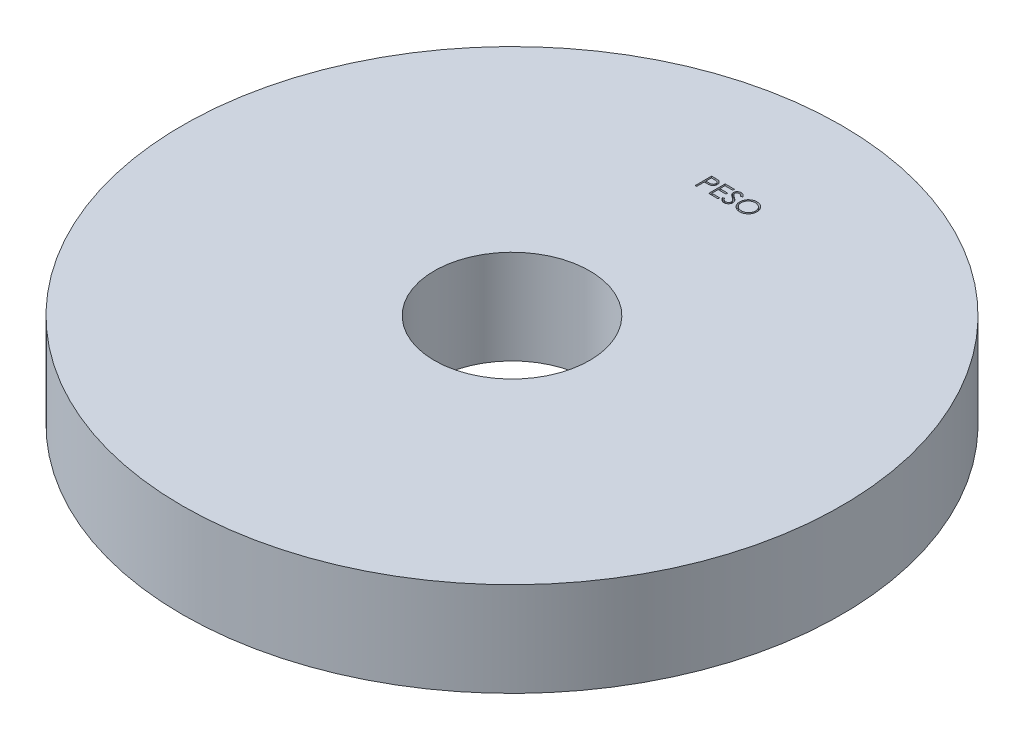
from build123d import *

# Parameters (mm, degrees)
ESBO_O1_R                = 70
ESBO_O1_R_2              = 16.5
RESSALTO_EXTRUS_O1_DEPTH = 20
CORTE_EXTRUS_O1_DEPTH    = 1


with BuildPart() as part:
    # Esboço1 → Ressalto-extrusão1 (new body)
    with BuildSketch(Plane(origin=(0, 0, 0), x_dir=(1, 0, 0), z_dir=(0, 1, 0))):
        Circle(ESBO_O1_R)
        Circle(ESBO_O1_R_2, mode=Mode.SUBTRACT)
    extrude(amount=RESSALTO_EXTRUS_O1_DEPTH)

    # Esboço2 → Corte-extrusão1 (cut)
    with BuildSketch(Plane(origin=(0, 20, 0), x_dir=(1, 0, 0), z_dir=(0, 1, 0))):
        with BuildLine():
            Line((-4.472641092, 46.873564993), (-3.786242854, 46.873564993))
            add(Edge.make_bspline(
                [(-3.786242854, 46.873564993), (-3.739031948, 46.873513097), (-3.648573755, 46.873413661), (-3.5188587, 46.870398916), (-3.401048968, 46.866372224), (-3.295398587, 46.86079033), (-3.201582489, 46.85419374), (-3.12002519, 46.844941701), (-3.050085633, 46.835281405), (-3.008179184, 46.825459999), (-2.989067374, 46.820980859)],
                knots=[0, 0, 0, 0, 0.000141628, 0.000271366, 0.00038923, 0.000495248, 0.00058876, 0.000671296, 0.000741499, 0.00080036, 0.00080036, 0.00080036, 0.00080036], degree=3))
            add(Edge.make_bspline(
                [(-2.989067374, 46.820980859), (-2.96487384, 46.814358909), (-2.917056863, 46.801271047), (-2.848155819, 46.775057324), (-2.782601974, 46.743975158), (-2.720170416, 46.708551219), (-2.661628332, 46.667265654), (-2.606102292, 46.621792037), (-2.554082311, 46.571080468), (-2.505860919, 46.515699728), (-2.461576122, 46.456579518), (-2.423446439, 46.392837288), (-2.391519212, 46.325545985), (-2.364135941, 46.254752414), (-2.344427486, 46.17986209), (-2.329580586, 46.101395378), (-2.320156959, 46.019360688), (-2.319254397, 45.96330082), (-2.318794938, 45.93476291)],
                knots=[0, 0, 0, 0, 7.5216e-05, 0.00014866, 0.000220794, 0.000292713, 0.000363707, 0.000435434, 0.000507823, 0.000581364, 0.000655543, 0.000729131, 0.000803767, 0.000878771, 0.000956497, 0.001035702, 0.001118238, 0.001203821, 0.001203821, 0.001203821, 0.001203821], degree=3))
            add(Edge.make_bspline(
                [(-2.318794938, 45.93476291), (-2.319216362, 45.905985133), (-2.320040908, 45.849679469), (-2.329937194, 45.767306681), (-2.343267385, 45.688588291), (-2.363764438, 45.61369884), (-2.390610111, 45.54308307), (-2.422102164, 45.475661838), (-2.460085694, 45.412582166), (-2.503730524, 45.353615048), (-2.552282118, 45.298705136), (-2.605535056, 45.248250342), (-2.663274349, 45.202546003), (-2.725316497, 45.161489659), (-2.792266346, 45.12603338), (-2.863108499, 45.094276075), (-2.938458716, 45.067605014), (-2.99060123, 45.053574953), (-3.017112245, 45.046441596)],
                knots=[0, 0, 0, 0, 8.6284e-05, 0.00016882, 0.000248587, 0.000325638, 0.000401297, 0.000474998, 0.000548586, 0.000621785, 0.0006948, 0.0007682, 0.000841564, 0.000915458, 0.000991056, 0.00106858, 0.00114819, 0.001230532, 0.001230532, 0.001230532, 0.001230532], degree=3))
            add(Edge.make_bspline(
                [(-3.017112245, 45.046441596), (-3.039039579, 45.041778615), (-3.087094607, 45.031559421), (-3.166237329, 45.020150964), (-3.258382715, 45.010413363), (-3.363404995, 45.003112225), (-3.4812099, 44.996861857), (-3.611861157, 44.991893763), (-3.755615234, 44.989163909), (-3.855886478, 44.989023116), (-3.908238047, 44.988949609)],
                knots=[0, 0, 0, 0, 6.7238e-05, 0.000147357, 0.000239727, 0.000345177, 0.000463135, 0.000593636, 0.000737393, 0.000894446, 0.000894446, 0.000894446, 0.000894446], degree=3))
            Line((-3.908238047, 44.988949609), (-4.158538527, 44.988949609))
            Line((-4.158538527, 44.988949609), (-4.158538527, 43.373564993))
            Line((-4.158538527, 43.373564993), (-4.472641092, 43.373564993))
            Line((-4.472641092, 43.373564993), (-4.472641092, 46.873564993))
        make_face()
        with BuildLine():
            Line((-4.158538527, 46.514590634), (-4.158538527, 45.347923968))
            Line((-4.158538527, 45.347923968), (-3.545758079, 45.340211628))
            add(Edge.make_bspline(
                [(-3.545758079, 45.340211628), (-3.515838153, 45.340196164), (-3.458078353, 45.340166312), (-3.37464213, 45.344151536), (-3.297232842, 45.348752068), (-3.226088267, 45.355487992), (-3.161176333, 45.365009249), (-3.102388804, 45.374620987), (-3.050181521, 45.38852635), (-2.989082319, 45.407249419), (-2.920998972, 45.439182034), (-2.846931423, 45.485531925), (-2.784160837, 45.544612633), (-2.72984254, 45.611040464), (-2.686736662, 45.684939593), (-2.65518067, 45.76400853), (-2.636639512, 45.84743638), (-2.634153319, 45.904524519), (-2.632897502, 45.933360666)],
                knots=[0, 0, 0, 0, 8.9746e-05, 0.000173253, 0.000250533, 0.00032239, 0.000387534, 0.00044736, 0.000500926, 0.000549486, 0.000638903, 0.000725641, 0.000810488, 0.000896226, 0.000982324, 0.00106604, 0.001150757, 0.001237226, 0.001237226, 0.001237226, 0.001237226], degree=3))
            add(Edge.make_bspline(
                [(-2.632897502, 45.933360666), (-2.634160148, 45.96149918), (-2.636670133, 46.017435062), (-2.655325996, 46.099413822), (-2.68667531, 46.177649527), (-2.730131905, 46.250622612), (-2.782873035, 46.316811416), (-2.844172378, 46.374308543), (-2.913885639, 46.420530246), (-2.97873387, 46.450363528), (-3.036335056, 46.468578803), (-3.086367016, 46.481323644), (-3.142857691, 46.49149925), (-3.20582547, 46.499738753), (-3.274782304, 46.506792214), (-3.350320619, 46.511578191), (-3.432154262, 46.514379647), (-3.488964833, 46.514518602), (-3.518414329, 46.514590634)],
                knots=[0, 0, 0, 0, 8.4371e-05, 0.000167719, 0.000250783, 0.000336277, 0.000421575, 0.000503926, 0.000587348, 0.000671427, 0.000717102, 0.000768457, 0.000826213, 0.000889178, 0.000958942, 0.001034123, 0.001116202, 0.001204546, 0.001204546, 0.001204546, 0.001204546], degree=3))
            Line((-3.518414329, 46.514590634), (-4.158538527, 46.514590634))
        make_face(mode=Mode.SUBTRACT)
        Polygon((-1.60084622, 46.873564993), (0.373512755, 46.873564993), (0.373512755, 46.514590634), (-1.286743656, 46.514590634), (-1.286743656, 45.437667557), (0.373512755, 45.437667557), (0.373512755, 45.078693198), (-1.286743656, 45.078693198), (-1.286743656, 43.732539352), (0.373512755, 43.732539352), (0.373512755, 43.373564993), (-1.60084622, 43.373564993), align=None)
        with BuildLine():
            Line((0.642743524, 44.048745282), (0.938616921, 44.226129096))
            add(Edge.make_bspline(
                [(0.938616921, 44.226129096), (0.966135159, 44.180064711), (1.018859039, 44.091807127), (1.106810398, 43.972549086), (1.197943309, 43.87118693), (1.292932643, 43.788310322), (1.391198591, 43.723061435), (1.493382645, 43.676859204), (1.599140456, 43.648043228), (1.671114277, 43.644543142), (1.707046408, 43.642795762)],
                knots=[0, 0, 0, 0, 0.000160901, 0.00030828, 0.000443778, 0.00056903, 0.000685513, 0.000796284, 0.00090427, 0.001011928, 0.001011928, 0.001011928, 0.001011928], degree=3))
            add(Edge.make_bspline(
                [(1.707046408, 43.642795762), (1.737733269, 43.643650435), (1.798570042, 43.645344825), (1.888132285, 43.661625627), (1.975114087, 43.686637756), (2.057722725, 43.722458688), (2.13481834, 43.765797173), (2.202425035, 43.818143351), (2.260871148, 43.876749557), (2.308680263, 43.942132211), (2.345360298, 44.01244936), (2.373552366, 44.084625311), (2.38919744, 44.159793879), (2.391554193, 44.210404342), (2.392743524, 44.235944801)],
                knots=[0, 0, 0, 0, 9.1978e-05, 0.000182347, 0.000272202, 0.000362975, 0.000451852, 0.000536835, 0.000618639, 0.000699414, 0.000778765, 0.000855983, 0.0009312, 0.001007828, 0.001007828, 0.001007828, 0.001007828], degree=3))
            add(Edge.make_bspline(
                [(2.392743524, 44.235944801), (2.391269213, 44.265085651), (2.388272155, 44.32432474), (2.362940675, 44.411724393), (2.323091428, 44.498216963), (2.286328784, 44.551718228), (2.267242723, 44.57949448)],
                knots=[0, 0, 0, 0, 8.7281e-05, 0.000177429, 0.000270909, 0.000371844, 0.000371844, 0.000371844, 0.000371844], degree=3))
            add(Edge.make_bspline(
                [(2.267242723, 44.57949448), (2.251572108, 44.599541304), (2.218673614, 44.641627103), (2.162116101, 44.704272338), (2.095749987, 44.768890757), (2.021846432, 44.837949814), (1.937713343, 44.908237611), (1.845985829, 44.983105889), (1.74432197, 45.059707466), (1.673022473, 45.111080031), (1.636233107, 45.137587429)],
                knots=[0, 0, 0, 0, 7.6319e-05, 0.000160223, 0.000252933, 0.000354147, 0.000463581, 0.000581729, 0.000709336, 0.000845369, 0.000845369, 0.000845369, 0.000845369], degree=3))
            add(Edge.make_bspline(
                [(1.636233107, 45.137587429), (1.599409111, 45.163816017), (1.529004434, 45.213963079), (1.430545852, 45.288387363), (1.342501389, 45.356431232), (1.265262373, 45.418735245), (1.198862776, 45.475307849), (1.142779365, 45.525605788), (1.098440808, 45.570989349), (1.073785227, 45.600430691), (1.062715479, 45.613649128)],
                knots=[0, 0, 0, 0, 0.000135623, 0.000259301, 0.000370234, 0.000469439, 0.00055697, 0.000631911, 0.000695377, 0.00074709, 0.00074709, 0.00074709, 0.00074709], degree=3))
            add(Edge.make_bspline(
                [(1.062715479, 45.613649128), (1.047242934, 45.634250165), (1.016814097, 45.674764868), (0.976648092, 45.738089726), (0.942508929, 45.802912992), (0.915746597, 45.869408856), (0.893210378, 45.936643785), (0.878052447, 46.005495031), (0.86856105, 46.075653649), (0.867589064, 46.12286715), (0.867102498, 46.146501692)],
                knots=[0, 0, 0, 0, 7.727e-05, 0.000151962, 0.000224716, 0.000296717, 0.00036678, 0.0004372, 0.000507902, 0.000578771, 0.000578771, 0.000578771, 0.000578771], degree=3))
            add(Edge.make_bspline(
                [(0.867102498, 46.146501692), (0.868407707, 46.183531466), (0.870990227, 46.25679953), (0.892830745, 46.363830361), (0.927303638, 46.466016778), (0.975598526, 46.562347112), (1.037855879, 46.650313092), (1.109901853, 46.730926579), (1.19571334, 46.798695162), (1.289865963, 46.85790722), (1.392922335, 46.904253145), (1.500913238, 46.939214125), (1.61401031, 46.959023383), (1.690613445, 46.961866148), (1.729482306, 46.963308583)],
                knots=[0, 0, 0, 0, 0.000110999, 0.000219625, 0.000326272, 0.00043382, 0.000541574, 0.000648775, 0.000756959, 0.000868438, 0.000981703, 0.00109501, 0.001208203, 0.0013248, 0.0013248, 0.0013248, 0.0013248], degree=3))
            add(Edge.make_bspline(
                [(1.729482306, 46.963308583), (1.770726406, 46.961886031), (1.852747758, 46.95905703), (1.973396974, 46.934459499), (2.08955769, 46.893758827), (2.183000955, 46.847570169), (2.256133716, 46.801438753), (2.311906449, 46.759418929), (2.3684239, 46.711043821), (2.426141954, 46.656184574), (2.484082614, 46.594337823), (2.543106066, 46.525927134), (2.603350335, 46.451370579), (2.642106195, 46.398146078), (2.661974293, 46.370860666)],
                knots=[0, 0, 0, 0, 0.000123638, 0.000245877, 0.000367608, 0.000492088, 0.000557638, 0.000626769, 0.000701372, 0.00078072, 0.000865532, 0.000955497, 0.001051745, 0.001152989, 0.001152989, 0.001152989, 0.001152989], degree=3))
            Line((2.661974293, 46.370860666), (2.378019966, 46.155616275))
            add(Edge.make_bspline(
                [(2.378019966, 46.155616275), (2.360874034, 46.177704966), (2.327854977, 46.220242619), (2.27772549, 46.279813934), (2.230476842, 46.334230414), (2.183926442, 46.381495542), (2.140532811, 46.424197675), (2.098415768, 46.460757432), (2.058181417, 46.491533028), (2.007464506, 46.524376588), (1.943746788, 46.556933091), (1.863762252, 46.584482169), (1.780175977, 46.601037231), (1.723246345, 46.603226119), (1.694426216, 46.604334224)],
                knots=[0, 0, 0, 0, 8.3877e-05, 0.000161528, 0.000233552, 0.000299993, 0.000360485, 0.000416152, 0.000467195, 0.000512312, 0.000597287, 0.000681099, 0.000765389, 0.000851809, 0.000851809, 0.000851809, 0.000851809], degree=3))
            add(Edge.make_bspline(
                [(1.694426216, 46.604334224), (1.658269694, 46.603122524), (1.588545246, 46.600785875), (1.48955501, 46.575265889), (1.400461085, 46.535084029), (1.32390852, 46.478769051), (1.260171543, 46.412048058), (1.214066084, 46.335269203), (1.18631592, 46.250486801), (1.18292964, 46.191345144), (1.181205062, 46.16122525)],
                knots=[0, 0, 0, 0, 0.000108248, 0.000208746, 0.00030443, 0.000399793, 0.000492054, 0.00057947, 0.000666386, 0.000756591, 0.000756591, 0.000756591, 0.000756591], degree=3))
            add(Edge.make_bspline(
                [(1.181205062, 46.16122525), (1.181598189, 46.142473771), (1.182385085, 46.104940152), (1.193359883, 46.04948873), (1.207459212, 45.99417739), (1.229801843, 45.939254807), (1.260647147, 45.883760448), (1.301152323, 45.826738711), (1.352165635, 45.767687002), (1.391242647, 45.729279628), (1.411874133, 45.709001692)],
                knots=[0, 0, 0, 0, 5.616e-05, 0.000112411, 0.000169046, 0.000227244, 0.000289691, 0.000359134, 0.000436702, 0.000523463, 0.000523463, 0.000523463, 0.000523463], degree=3))
            add(Edge.make_bspline(
                [(1.411874133, 45.709001692), (1.419535505, 45.702164666), (1.437737172, 45.685921458), (1.471013098, 45.659329177), (1.514955896, 45.626526405), (1.568418098, 45.585939088), (1.632385459, 45.538857626), (1.706865015, 45.485884014), (1.791026548, 45.425298555), (1.850748464, 45.382941014), (1.882326857, 45.36054416)],
                knots=[0, 0, 0, 0, 3.0802e-05, 7.3177e-05, 0.000127725, 0.000195314, 0.000274544, 0.000365991, 0.000469501, 0.000585644, 0.000585644, 0.000585644, 0.000585644], degree=3))
            add(Edge.make_bspline(
                [(1.882326857, 45.36054416), (1.92031277, 45.3329028), (1.993867227, 45.279379139), (2.098524807, 45.198963459), (2.193418615, 45.12031569), (2.278881818, 45.043938083), (2.355758727, 44.97040999), (2.423196448, 44.89884681), (2.481882128, 44.829761237), (2.545061346, 44.741188661), (2.609619166, 44.632407577), (2.665060673, 44.499129338), (2.700019021, 44.365333018), (2.704590536, 44.275406181), (2.706846088, 44.231036948)],
                knots=[0, 0, 0, 0, 0.000140932, 0.000272896, 0.000395881, 0.000510584, 0.000616697, 0.000714904, 0.000805482, 0.000888372, 0.001041088, 0.001183793, 0.001320341, 0.001453327, 0.001453327, 0.001453327, 0.001453327], degree=3))
            add(Edge.make_bspline(
                [(2.706846088, 44.231036948), (2.70618895, 44.199658583), (2.704887435, 44.1375112), (2.689926521, 44.046256123), (2.668006856, 43.957625253), (2.634969622, 43.872714141), (2.594646464, 43.789969378), (2.543480216, 43.711561478), (2.484172531, 43.635755079), (2.416138766, 43.564571588), (2.341692864, 43.499225392), (2.263009169, 43.44109633), (2.179958896, 43.392628007), (2.092992579, 43.353077165), (2.002090243, 43.322143647), (1.907282459, 43.299730778), (1.808412948, 43.285975067), (1.741212466, 43.284547306), (1.707046408, 43.283821403)],
                knots=[0, 0, 0, 0, 9.4044e-05, 0.000186263, 0.000276729, 0.000367488, 0.000459046, 0.000552398, 0.000647774, 0.000747454, 0.000847311, 0.000944634, 0.001040472, 0.001135227, 0.001230788, 0.001328063, 0.00142712, 0.00152957, 0.00152957, 0.00152957, 0.00152957], degree=3))
            add(Edge.make_bspline(
                [(1.707046408, 43.283821403), (1.680611065, 43.284332585), (1.628073305, 43.28534851), (1.550363824, 43.294329791), (1.474224234, 43.307036894), (1.400609952, 43.327210964), (1.328572541, 43.351687941), (1.258425306, 43.381826274), (1.190134252, 43.417943475), (1.123316669, 43.4592385), (1.058142495, 43.507296245), (0.995223027, 43.563269741), (0.932493841, 43.625615246), (0.871806445, 43.696025809), (0.811933301, 43.773363892), (0.754054891, 43.858353076), (0.696973174, 43.950530429), (0.661157706, 44.015395515), (0.642743524, 44.048745282)],
                knots=[0, 0, 0, 0, 7.9276e-05, 0.000157554, 0.000234438, 0.000310629, 0.000386236, 0.000462555, 0.000539392, 0.000617798, 0.000698008, 0.000781971, 0.000870217, 0.00096315, 0.001060616, 0.001163492, 0.001271478, 0.00138575, 0.00138575, 0.00138575, 0.00138575], degree=3))
        make_face()
        with BuildLine():
            add(Edge.make_bspline(
                [(5.062615319, 46.963308583), (5.127423425, 46.961667104), (5.254711892, 46.958443103), (5.441786789, 46.933763999), (5.620381885, 46.891068609), (5.791952023, 46.834205627), (5.954445, 46.758351241), (6.109083892, 46.666666093), (6.255500766, 46.558189634), (6.391722148, 46.433760407), (6.516379098, 46.298376953), (6.626204984, 46.153899043), (6.718247278, 46.001200241), (6.793833065, 45.84073941), (6.853131675, 45.672879442), (6.894050719, 45.49672544), (6.920188869, 45.31341875), (6.923244646, 45.188391885), (6.924794806, 45.124967237)],
                knots=[0, 0, 0, 0, 0.000194393, 0.000381804, 0.00056479, 0.000744601, 0.000923091, 0.001101652, 0.001283106, 0.001468738, 0.001654324, 0.001834514, 0.002012231, 0.002188181, 0.002365797, 0.002545211, 0.002729936, 0.002920126, 0.002920126, 0.002920126, 0.002920126], degree=3))
            add(Edge.make_bspline(
                [(6.924794806, 45.124967237), (6.923244873, 45.06200979), (6.920189777, 44.93791337), (6.894020999, 44.755769926), (6.852979999, 44.580679229), (6.794383733, 44.412933577), (6.719158255, 44.252356013), (6.626503084, 44.099369059), (6.517361873, 43.953922561), (6.393155022, 43.817609895), (6.25775398, 43.692612425), (6.112523713, 43.583693549), (5.960730393, 43.489969424), (5.800420685, 43.41518575), (5.633720648, 43.35541383), (5.459138325, 43.3146612), (5.277491771, 43.288374157), (5.153620767, 43.285355641), (5.090660191, 43.283821403)],
                knots=[0, 0, 0, 0, 0.000188789, 0.000372126, 0.000550857, 0.00072758, 0.000904164, 0.001081881, 0.001263191, 0.001448823, 0.00163441, 0.001815159, 0.001992641, 0.002168591, 0.002344885, 0.002522934, 0.002705576, 0.002894365, 0.002894365, 0.002894365, 0.002894365], degree=3))
            add(Edge.make_bspline(
                [(5.090660191, 43.283821403), (5.027235872, 43.28537079), (4.902209656, 43.288425044), (4.71867262, 43.314606449), (4.542394876, 43.355547753), (4.373880525, 43.414057189), (4.213035596, 43.48967442), (4.059545513, 43.581878799), (3.914026366, 43.69128594), (3.777684619, 43.815452515), (3.652935421, 43.950624067), (3.544176045, 44.095458322), (3.451950932, 44.247113778), (3.376587599, 44.406011302), (3.31692314, 44.571382745), (3.276218322, 44.744331223), (3.24988237, 44.923870728), (3.246847523, 45.046113627), (3.245307626, 45.108140314)],
                knots=[0, 0, 0, 0, 0.00019019, 0.000374915, 0.000555011, 0.000732396, 0.00090898, 0.001087298, 0.001268608, 0.00145424, 0.001639827, 0.001819595, 0.001996712, 0.002171394, 0.002346367, 0.002523053, 0.002703612, 0.002889599, 0.002889599, 0.002889599, 0.002889599], degree=3))
            add(Edge.make_bspline(
                [(3.245307626, 45.108140314), (3.245842262, 45.149772983), (3.246904788, 45.232513106), (3.259696481, 45.355379706), (3.278258182, 45.476270364), (3.304860094, 45.594841312), (3.339651761, 45.710802297), (3.380703789, 45.82495306), (3.430843634, 45.936136783), (3.487524282, 46.044880175), (3.55078609, 46.149488081), (3.62066184, 46.248367664), (3.694697208, 46.342348661), (3.775860602, 46.428995665), (3.861477047, 46.510829321), (3.952935425, 46.586592038), (4.04967767, 46.656966989), (4.152120049, 46.72038733), (4.257738324, 46.777746465), (4.366615102, 46.826968316), (4.477271673, 46.869214377), (4.590226321, 46.903455203), (4.705179093, 46.930487239), (4.822380878, 46.948894592), (4.941738304, 46.96171891), (5.022149623, 46.962776412), (5.062615319, 46.963308583)],
                knots=[0, 0, 0, 0, 0.000124849, 0.000248123, 0.000370193, 0.00049164, 0.000612319, 0.000733199, 0.000855287, 0.000977905, 0.001100913, 0.001221706, 0.001340948, 0.001459521, 0.001577551, 0.001696047, 0.001815534, 0.001936153, 0.002057243, 0.002175846, 0.002294342, 0.002412335, 0.002529682, 0.00264829, 0.002768075, 0.00288942, 0.00288942, 0.00288942, 0.00288942], degree=3))
        make_face()
        with BuildLine():
            add(Edge.make_bspline(
                [(5.078039998, 46.604334224), (5.044825365, 46.603929334), (4.978713632, 46.603123424), (4.880429095, 46.592507708), (4.783437162, 46.577377819), (4.687717799, 46.555796299), (4.59367151, 46.526392246), (4.500421669, 46.492551338), (4.408818615, 46.451330247), (4.319164757, 46.404757543), (4.232249682, 46.353208622), (4.150236981, 46.296236855), (4.072914337, 46.235178301), (4.00047107, 46.169890463), (3.933119898, 46.100040861), (3.869535196, 46.026688425), (3.812265615, 45.947736534), (3.759780038, 45.865326127), (3.712812198, 45.779564546), (3.671046843, 45.691354684), (3.636882834, 45.599976997), (3.609020458, 45.50642284), (3.585920647, 45.41084038), (3.571286723, 45.312504531), (3.560554363, 45.211909419), (3.559794518, 45.143927565), (3.559410191, 45.109542557)],
                knots=[0, 0, 0, 0, 9.9599e-05, 0.000198245, 0.000296222, 0.00039402, 0.00049227, 0.000591646, 0.000691452, 0.000793368, 0.000894612, 0.000994383, 0.001092713, 0.00119001, 0.001286696, 0.001383657, 0.001480979, 0.001579008, 0.001676595, 0.001774142, 0.001871547, 0.001968922, 0.002066879, 0.00216624, 0.00226698, 0.002370083, 0.002370083, 0.002370083, 0.002370083], degree=3))
            add(Edge.make_bspline(
                [(3.559410191, 45.109542557), (3.560685052, 45.058980336), (3.5631931, 44.959508806), (3.58515067, 44.813740662), (3.618972645, 44.673652376), (3.668830011, 44.540010467), (3.731180626, 44.411666184), (3.808207516, 44.289758079), (3.899466602, 44.174253205), (4.003130128, 44.065957936), (4.116452835, 43.967112132), (4.236785565, 43.880348723), (4.362839172, 43.806938473), (4.494942375, 43.747133401), (4.632389914, 43.699743663), (4.776067465, 43.667265032), (4.925017925, 43.645889576), (5.02654858, 43.643836821), (5.078039998, 43.642795762)],
                knots=[0, 0, 0, 0, 0.000151605, 0.000298253, 0.000441263, 0.000583229, 0.000725274, 0.000868635, 0.001014928, 0.001166177, 0.001317744, 0.00146543, 0.001610576, 0.001754594, 0.001899821, 0.002045914, 0.002195936, 0.002350312, 0.002350312, 0.002350312, 0.002350312], degree=3))
            add(Edge.make_bspline(
                [(5.078039998, 43.642795762), (5.1126495, 43.643271267), (5.181290536, 43.644214335), (5.283386059, 43.653713012), (5.38364227, 43.668944881), (5.48191855, 43.690875537), (5.578103362, 43.718322743), (5.672598165, 43.750930471), (5.764396455, 43.791611675), (5.854656293, 43.836559626), (5.941052534, 43.887799784), (6.023528067, 43.942837933), (6.100004047, 44.003806554), (6.172393118, 44.068124367), (6.240020807, 44.137088215), (6.302429791, 44.210608436), (6.359409923, 44.289149094), (6.41187557, 44.371434499), (6.458678833, 44.457430752), (6.499457932, 44.54596043), (6.534054048, 44.636805539), (6.561982552, 44.730097111), (6.583868014, 44.82565796), (6.598947934, 44.923616038), (6.609496373, 45.02377538), (6.61029145, 45.091519236), (6.610692242, 45.125668359)],
                knots=[0, 0, 0, 0, 0.000103804, 0.000205874, 0.000307314, 0.000407849, 0.000507719, 0.000607281, 0.000707445, 0.000808723, 0.000909609, 0.001008589, 0.001105934, 0.001202762, 0.001298946, 0.001395452, 0.001491794, 0.001589823, 0.001688026, 0.001785277, 0.001882027, 0.001979402, 0.0020772, 0.002175869, 0.002276609, 0.002379011, 0.002379011, 0.002379011, 0.002379011], degree=3))
            add(Edge.make_bspline(
                [(6.610692242, 45.125668359), (6.610291129, 45.159583863), (6.609495447, 45.226861513), (6.598952973, 45.326322331), (6.583852082, 45.423575543), (6.562089374, 45.518239346), (6.534039221, 45.610337871), (6.49945189, 45.699784619), (6.458666591, 45.786912814), (6.411858366, 45.871507111), (6.359242543, 45.952681849), (6.3017483, 46.030284261), (6.238382951, 46.102857003), (6.170956927, 46.172191697), (6.097786041, 46.236809586), (6.019201747, 46.296732107), (5.936158069, 46.353405381), (5.848230834, 46.404530943), (5.75748688, 46.451745176), (5.664372922, 46.492196179), (5.569943823, 46.526568298), (5.47443971, 46.555885263), (5.377056732, 46.577293293), (5.278452903, 46.592521343), (5.178764645, 46.603119729), (5.111721425, 46.603928108), (5.078039998, 46.604334224)],
                knots=[0, 0, 0, 0, 0.000101701, 0.000201743, 0.00029972, 0.000396835, 0.000492868, 0.000588308, 0.000684288, 0.000781261, 0.000878109, 0.000974304, 0.001070733, 0.001166917, 0.001264269, 0.001363274, 0.001463228, 0.001565678, 0.001668217, 0.001769947, 0.001869982, 0.001969573, 0.002069423, 0.002168785, 0.002268827, 0.002369827, 0.002369827, 0.002369827, 0.002369827], degree=3))
        make_face(mode=Mode.SUBTRACT)
    extrude(amount=-CORTE_EXTRUS_O1_DEPTH, mode=Mode.SUBTRACT)


solid = part.part
